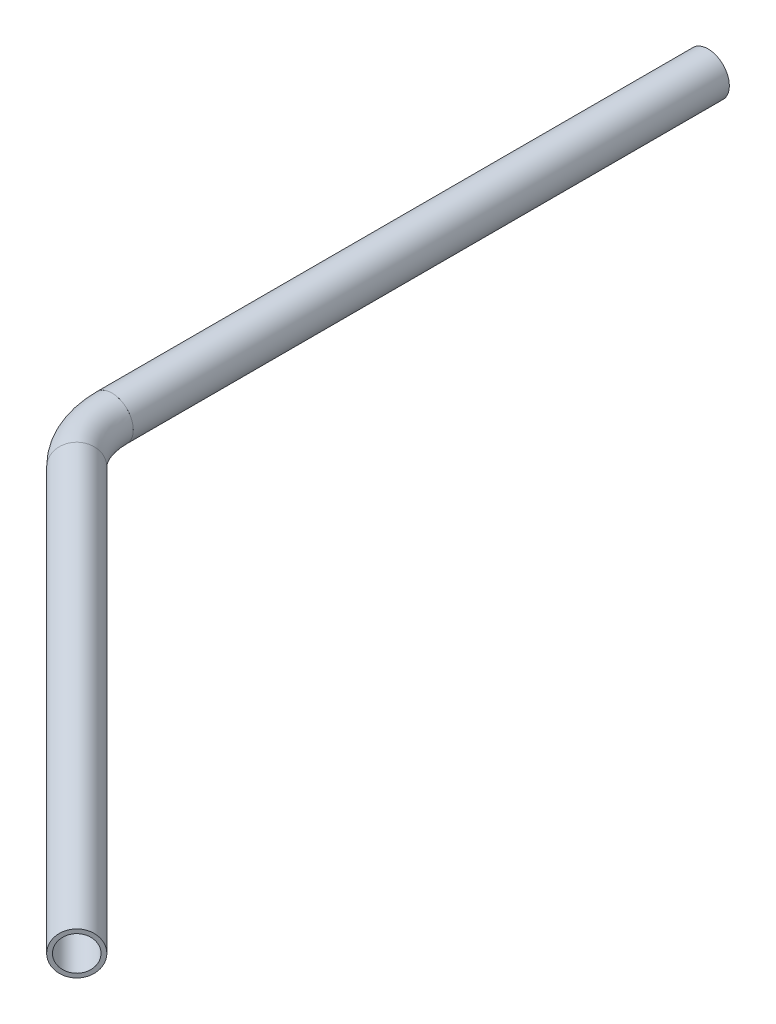
from build123d import *

# Parameters (mm, degrees)
SKIZZE1_ON_SEGMENT_1_R   = 16.85
SKIZZE1_ON_SEGMENT_1_R_2 = 13.6
STRUKTURBAUTEIL2_DEPTH   = 472.082005896
SKIZZE1_ON_SEGMENT_2_R   = 16.85
SKIZZE1_ON_SEGMENT_2_R_2 = 13.6
STRUKTURBAUTEIL2_2_ANGLE = 45
SKIZZE1_R                = 16.85
SKIZZE1_R_2              = 13.6
STRUKTURBAUTEIL2_3_DEPTH = 472.082005896


with BuildPart() as part:
    # Skizze1 on segment 1 (carried to segment 1) → Strukturbauteil2 (new body)
    with BuildSketch(Plane(origin=(19.741002948, 0, 19.741002948), x_dir=(0.707106781, 0, -0.707106781), z_dir=(0.707106781, 0, 0.707106781))):
        Circle(SKIZZE1_ON_SEGMENT_1_R)
        Circle(SKIZZE1_ON_SEGMENT_1_R_2, mode=Mode.SUBTRACT)
    extrude(amount=STRUKTURBAUTEIL2_DEPTH)


with BuildPart() as body_2:
    # Skizze1 on segment 2 (carried to the start of arc 2) → Strukturbauteil2 2 (revolve)
    with BuildSketch(Plane.XY.offset(-27.917994104)):
        Circle(SKIZZE1_ON_SEGMENT_2_R)
        Circle(SKIZZE1_ON_SEGMENT_2_R_2, mode=Mode.SUBTRACT)
    revolve(axis=Axis((67.4, 0, -27.917994104), (0, 1, 0)), revolution_arc=STRUKTURBAUTEIL2_2_ANGLE)


with BuildPart() as body_3:
    # Skizze1 → Strukturbauteil2 3 (new body)
    with BuildSketch(Plane(origin=(0, 0, -27.917994104), x_dir=(-1, 0, 0), z_dir=(0, 0, -1))):
        Circle(SKIZZE1_R)
        Circle(SKIZZE1_R_2, mode=Mode.SUBTRACT)
    extrude(amount=STRUKTURBAUTEIL2_3_DEPTH)


solid = Compound([part.part, body_2.part, body_3.part])
